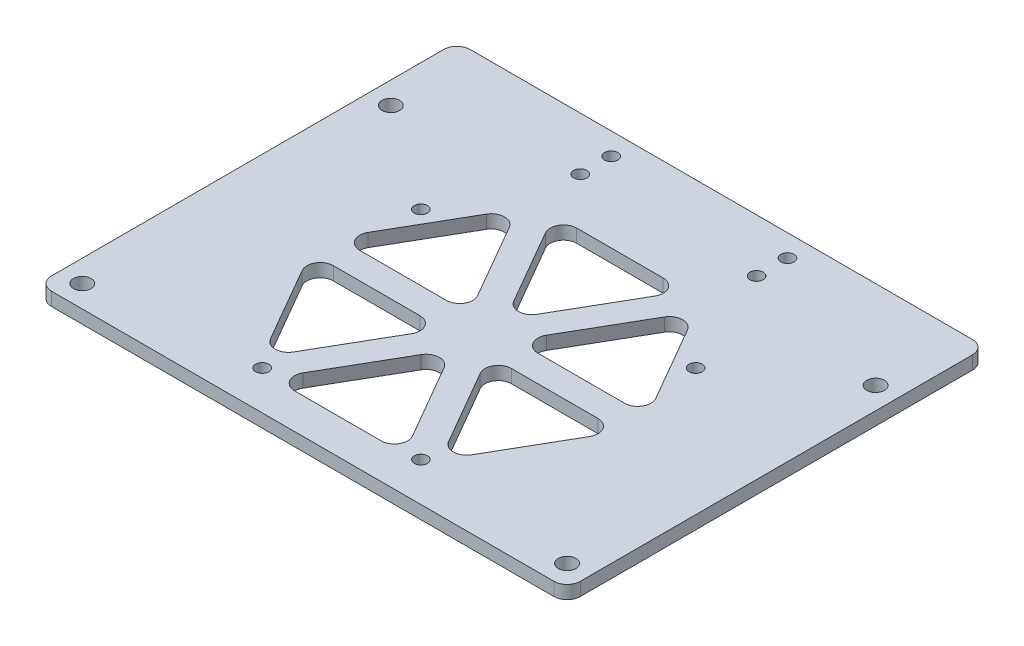
from build123d import *

# Parameters (mm, degrees)
SKETCH_1_W          = 120
SKETCH_1_H          = 80
EXTRUDE_1_DEPTH     = 3
SKETCH_3_R          = 1.5
CUT_EXTRUDE_2_DEPTH = 4
SKETCH_4_R          = 2
CUT_EXTRUDE_3_DEPTH = 4
SKETCH_5_W          = 120
SKETCH_5_H          = 3
EXTRUDE_2_DEPTH     = 15
CUT_EXTRUDE_4_DEPTH = 15
FILLET_1_R          = 3
SKETCH_7_R          = 1.5
CUT_EXTRUDE_5_DEPTH = 4
FILLET_2_R          = 3


with BuildPart() as part:
    # 草图1 → 凸台-拉伸1 (new body)
    with BuildSketch(Plane(origin=(0, 0, 0), x_dir=(1, 0, 0), z_dir=(0, 1, 0))):
        Rectangle(SKETCH_1_W, SKETCH_1_H)
    extrude(amount=EXTRUDE_1_DEPTH)

    # 草图3 → 切除-拉伸2 (cut, through all)
    with BuildSketch(Plane(origin=(0, 3, 0), x_dir=(1, 0, 0), z_dir=(0, 1, 0))):
        with Locations((-31.176914536, 18)):
            Circle(SKETCH_3_R)
        with Locations((31.176914536, 18)):
            Circle(SKETCH_3_R)
        with Locations((-18, -31.176914536)):
            Circle(SKETCH_3_R)
        with Locations((18, -31.176914536)):
            Circle(SKETCH_3_R)
    extrude(amount=-CUT_EXTRUDE_2_DEPTH, mode=Mode.SUBTRACT)

    # 草图4 → 切除-拉伸3 (cut, through all)
    with BuildSketch(Plane(origin=(0, 3, 0), x_dir=(1, 0, 0), z_dir=(0, 1, 0))):
        with Locations((-55, 35)):
            Circle(SKETCH_4_R)
        with Locations((55, 35)):
            Circle(SKETCH_4_R)
        with Locations((55, -35)):
            Circle(SKETCH_4_R)
        with Locations((-55, -35)):
            Circle(SKETCH_4_R)
    extrude(amount=-CUT_EXTRUDE_3_DEPTH, mode=Mode.SUBTRACT)

    # 草图5 → 凸台-拉伸2 (add)
    with BuildSketch(Plane(origin=(0, 0, -40), x_dir=(-1, 0, 0), z_dir=(0, 0, -1))):
        with Locations((0, 1.5)):
            Rectangle(SKETCH_5_W, SKETCH_5_H)
    extrude(amount=EXTRUDE_2_DEPTH)

    # 草图6 → 切除-拉伸4 (cut)
    with BuildSketch(Plane(origin=(0, 3, 0), x_dir=(1, 0, 0), z_dir=(0, 1, 0))):
        Polygon((-15.011106999, 32), (0, 6), (15.011106999, 32), align=None)
        Polygon((5.196152423, 3), (35.218366421, 3), (20.207259422, 29), align=None)
        Polygon((5.196152423, -3), (20.207259422, -29), (35.218366421, -3), align=None)
        Polygon((-15.011106999, -32), (15.011106999, -32), (0, -6), align=None)
        Polygon((-35.218366421, -3), (-20.207259422, -29), (-5.196152423, -3), align=None)
        Polygon((-35.218366421, 3), (-5.196152423, 3), (-20.207259422, 29), align=None)
    extrude(amount=-CUT_EXTRUDE_4_DEPTH, mode=Mode.SUBTRACT)

    # 圆角1
    fillet_1_edges = [part.edges().sort_by_distance(p)[0] for p in [
        (35.218366421, 1.5, -3),
        (5.196152423, 1.5, -3),
        (20.207259422, 1.5, -29),
        (-20.207259422, 1.5, -29),
        (-5.196152423, 1.5, -3),
        (-35.218366421, 1.5, -3),
        (15.011106999, 1.5, -32),
        (0, 1.5, -6),
        (-15.011106999, 1.5, -32),
        (-15.011106999, 1.5, 32),
        (0, 1.5, 6),
        (15.011106999, 1.5, 32),
        (-35.218366421, 1.5, 3),
        (-5.196152423, 1.5, 3),
        (-20.207259422, 1.5, 29),
        (20.207259422, 1.5, 29),
        (5.196152423, 1.5, 3),
        (35.218366421, 1.5, 3),
    ]]
    fillet(fillet_1_edges, radius=FILLET_1_R)

    # 草图7 → 切除-拉伸5 (cut, through all)
    with BuildSketch(Plane(origin=(0, 3, 0), x_dir=(1, 0, 0), z_dir=(0, 1, 0))):
        with Locations((-20, 50)):
            Circle(SKETCH_7_R)
        with Locations((20, 50)):
            Circle(SKETCH_7_R)
        with Locations((-20, 43)):
            Circle(SKETCH_7_R)
        with Locations((20, 43)):
            Circle(SKETCH_7_R)
    extrude(amount=-CUT_EXTRUDE_5_DEPTH, mode=Mode.SUBTRACT)

    # 圆角2
    fillet_2_edges = [part.edges().sort_by_distance(p)[0] for p in [
        (60, 1.5, -55),
        (-60, 1.5, -55),
        (60, 1.5, 40),
        (-60, 1.5, 40),
    ]]
    fillet(fillet_2_edges, radius=FILLET_2_R)


solid = part.part
